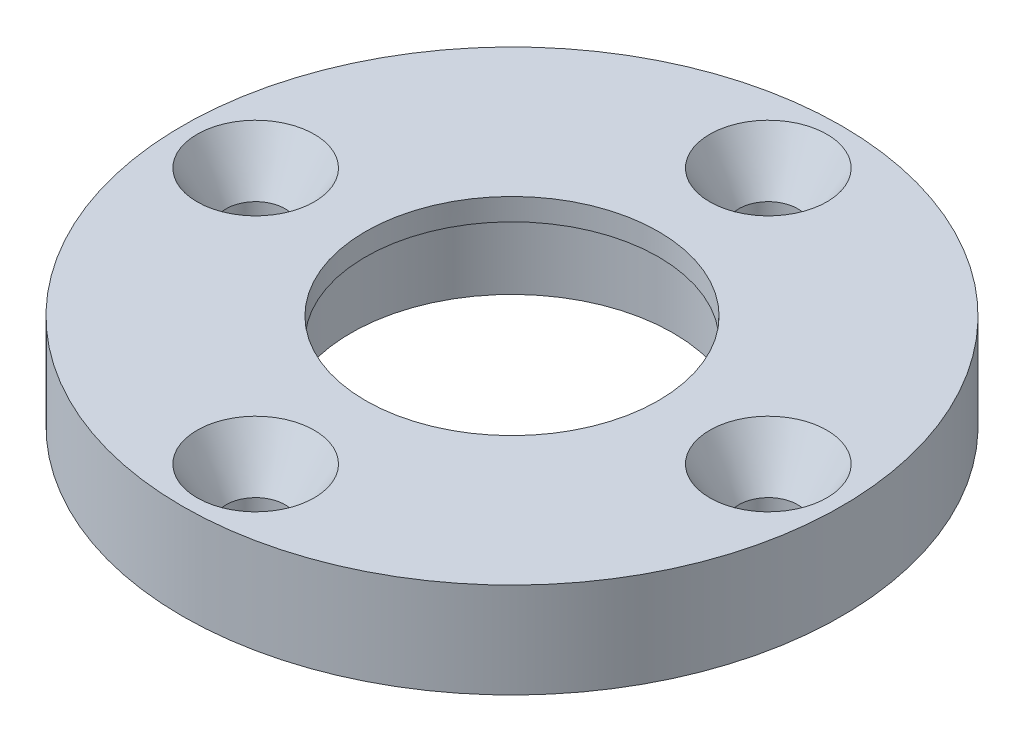
from build123d import *

# Parameters (mm, degrees)
SKETCH_1_R          = 22.5
SKETCH_1_R_2        = 10
EXTRUDE_1_DEPTH     = 6.5
SKETCH_2_R          = 2
CUT_EXTRUDE_1_DEPTH = 7.5
SKETCH_3_R          = 11
CUT_EXTRUDE_2_DEPTH = 5
CHAMFER_1_SIZE      = 2
CHAMFER_1_SIZE2     = 3.4


with BuildPart() as part:
    # 草图1 → 凸台-拉伸1 (new body)
    with BuildSketch(Plane(origin=(0, 0, 0), x_dir=(1, 0, 0), z_dir=(0, 1, 0))):
        Circle(SKETCH_1_R)
        Circle(SKETCH_1_R_2, mode=Mode.SUBTRACT)
    extrude(amount=EXTRUDE_1_DEPTH)

    # 草图2 → 切除-拉伸1 (cut, through all)
    with BuildSketch(Plane(origin=(0, 6.5, 0), x_dir=(1, 0, 0), z_dir=(0, 1, 0))):
        with Locations((0, 17.5)):
            Circle(SKETCH_2_R)
        with Locations((17.5, 0)):
            Circle(SKETCH_2_R)
        with Locations((0, -17.5)):
            Circle(SKETCH_2_R)
        with Locations((-17.5, 0)):
            Circle(SKETCH_2_R)
    extrude(amount=-CUT_EXTRUDE_1_DEPTH, mode=Mode.SUBTRACT)

    # 草图3 → 切除-拉伸2 (cut)
    with BuildSketch(Plane.XZ):
        Circle(SKETCH_3_R)
    extrude(amount=-CUT_EXTRUDE_2_DEPTH, mode=Mode.SUBTRACT)

    # 倒角1
    chamfer_1_edges = [part.edges().sort_by_distance(p)[0] for p in [
        (-2, 6.5, -17.5),
        (15.5, 6.5, 0),
        (-2, 6.5, 17.5),
        (-19.5, 6.5, 0),
    ]]
    chamfer_1_side = [part.faces().sort_by_distance(p)[0] for p in [
        (-21.863603897, 6.5, 0),
    ]]
    chamfer(chamfer_1_edges, length=CHAMFER_1_SIZE, length2=CHAMFER_1_SIZE2, reference=chamfer_1_side[0])


solid = part.part
